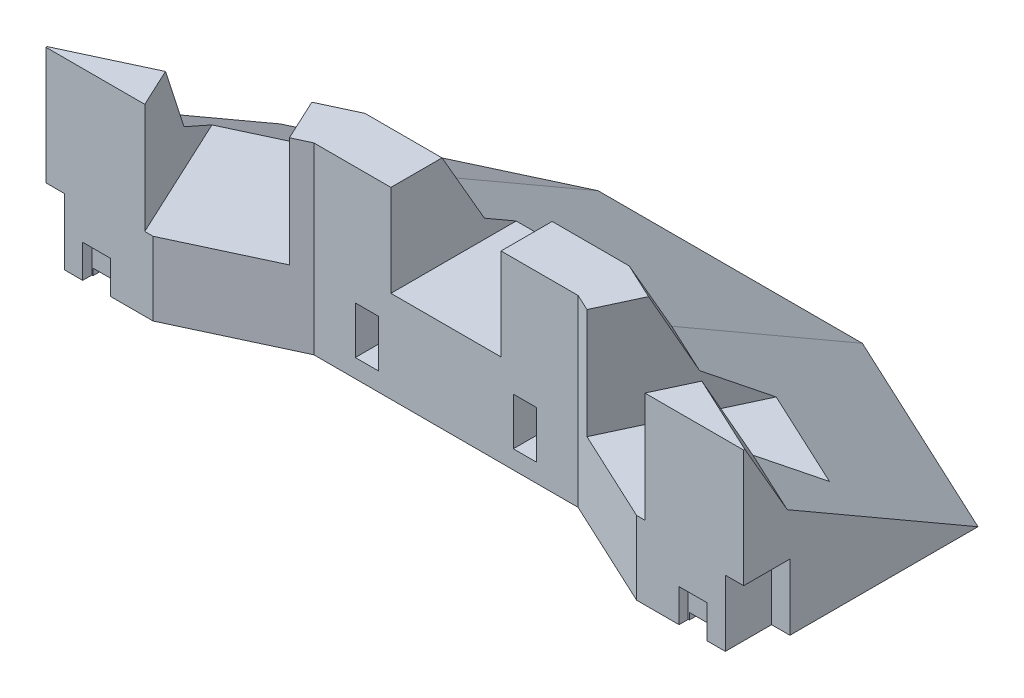
from build123d import *

# Parameters (mm, degrees)
SALIENTE_EXTRUIR1_DEPTH            = 50
CORTAR_EXTRUIR1_DEPTH              = 72
CORTAR_EXTRUIR4_REACH              = 144.211
CROQUIS6_W                         = 30
CROQUIS6_H                         = 25
CORTAR_EXTRUIR5_REACH              = 144.211
CROQUIS8_W                         = 30
CROQUIS8_H                         = 30
CORTAR_EXTRUIR6_DEPTH              = 40
CROQUIS9_W                         = 30
CROQUIS9_H                         = 30
CORTAR_EXTRUIR7_DEPTH              = 40
CROQUIS10_W                        = 6.35
CROQUIS10_H                        = 12.9
CORTAR_EXTRUIR8_DEPTH              = 33
CORTAR_EXTRUIR9_REACH              = 144.211
CORTAR_EXTRUIR10_REACH             = 144.211
CORTAR_EXTRUIR10_DIRECTION_2_DEPTH = 143.210791725
CROQUIS14_W                        = 12.6
CROQUIS14_H                        = 18
CORTAR_EXTRUIR11_DEPTH             = 5
CROQUIS15_W                        = 12.517773713
CROQUIS15_H                        = 18.001366708
CORTAR_EXTRUIR12_DEPTH             = 5
CROQUIS16_W                        = 7.6
CROQUIS16_H                        = 2.5
CORTAR_EXTRUIR13_DEPTH             = 9
CORTAR_EXTRUIR14_DEPTH             = 1.8


with BuildPart() as part:
    # Croquis1 → Saliente-Extruir1 (new body)
    with BuildSketch(Plane(origin=(0, 0, 0), x_dir=(1, 0, 0), z_dir=(0, 1, 0))):
        Polygon((-96.830741331, 0), (96.830741331, 0), (96.830741331, 63), (36, 91.365840534), (-36, 91.365840534), (-96.830741331, 63), align=None)
    extrude(amount=SALIENTE_EXTRUIR1_DEPTH)

    # Croquis3D2 → Cortar-Extruir1 (cut)
    with BuildSketch(Plane(origin=(-36, 0, -91.365840534), x_dir=(0, 0.6600783810393928, 0.751196732477195), z_dir=(-1, 0, 0))):
        Polygon((0, 0), (58.835678645, -11.762776814), (93.598994681, 0), (40.781406688, 46.410941988), align=None)
    extrude(amount=-CORTAR_EXTRUIR1_DEPTH, mode=Mode.SUBTRACT)

    # Cortar-Barrer1: sweep along a curve in space
    with BuildLine() as cortar_barrer1_path:
        Line((96.830741331, 50, -63), (36, 50, -91.365840534))
    # Croquis2 → Cortar-Barrer1 (sweep, cut)
    with BuildSketch(Plane.ZY.offset(-36)):
        Polygon((-91.365840534, 50), (-27.857310923, 50), (-39.404316307, 30), (-91.365840534, 0), align=None)
    sweep(path=cortar_barrer1_path.line, mode=Mode.SUBTRACT)

    # Cortar-Barrer2: sweep along a curve in space
    with BuildLine() as cortar_barrer2_path:
        Line((-36, 50, -91.365840534), (-96.830741331, 50, -63))
    # Croquis3 → Cortar-Barrer2 (sweep, cut)
    with BuildSketch(Plane(origin=(-36, 0, 0), x_dir=(0, 0, -1), z_dir=(1, 0, 0))):
        Polygon((27.857310923, 50), (91.365840534, 50), (91.365840534, 0), (39.404316307, 30), align=None)
    sweep(path=cortar_barrer2_path.line, mode=Mode.SUBTRACT)

    # Croquis6 → Cortar-Extruir4 (cut, up to next)
    with BuildSketch(Plane.XY, mode=Mode.PRIVATE) as cortar_extruir4_sk1:
        with Locations((0, 37.5)):
            Rectangle(CROQUIS6_W, CROQUIS6_H)
    cortar_extruir4_tool1 = extrude(cortar_extruir4_sk1.sketch, amount=-CORTAR_EXTRUIR4_REACH, mode=Mode.PRIVATE) & part.part
    add(cortar_extruir4_tool1.solids().sort_by_distance((0, 37.5, 0))[0], mode=Mode.SUBTRACT)

    # Croquis7 → Cortar-Extruir5 (cut, up to next)
    with BuildSketch(Plane(origin=(0, 50, 0), x_dir=(1, 0, 0), z_dir=(0, 1, 0)), mode=Mode.PRIVATE) as cortar_extruir5_sk1:
        Polygon((-36, 13.928655461), (36, 13.928655461), (65.87009803, 0), (-65.87009803, 0), align=None)
    cortar_extruir5_tool1 = extrude(cortar_extruir5_sk1.sketch, amount=-CORTAR_EXTRUIR5_REACH, mode=Mode.PRIVATE) & part.part
    add(cortar_extruir5_tool1.solids().sort_by_distance((0, 50, -6.28364))[0], mode=Mode.SUBTRACT)

    # Croquis8 → Cortar-Extruir6 (cut)
    with BuildSketch(Plane(origin=(-11.764807584, 0, -25.229711282), x_dir=(0.9063077870366527, 0, -0.4226182617406937), z_dir=(0.4226182617406937, 0, 0.9063077870366527))):
        with Locations((-46.740576174, 35)):
            Rectangle(CROQUIS8_W, CROQUIS8_H)
    extrude(amount=-CORTAR_EXTRUIR6_DEPTH, mode=Mode.SUBTRACT)

    # Croquis9 → Cortar-Extruir7 (cut)
    with BuildSketch(Plane(origin=(11.764807584, 0, -25.229711282), x_dir=(0.9063077870366495, 0, 0.42261826174070066), z_dir=(-0.42261826174070066, 0, 0.9063077870366495))):
        with Locations((46.740576174, 35)):
            Rectangle(CROQUIS9_W, CROQUIS9_H)
    extrude(amount=-CORTAR_EXTRUIR7_DEPTH, mode=Mode.SUBTRACT)

    # Croquis10 → Cortar-Extruir8 (cut)
    with BuildSketch(Plane.XY.offset(-13.928655461)):
        with Locations((-21.525, 11.451366708)):
            Rectangle(CROQUIS10_W, CROQUIS10_H)
        with Locations((21.525, 11.451366708)):
            Rectangle(CROQUIS10_W, CROQUIS10_H)
    extrude(amount=-CORTAR_EXTRUIR8_DEPTH, mode=Mode.SUBTRACT)

    # Croquis12 → Cortar-Extruir9 (cut, up to next)
    with BuildSketch(Plane(origin=(0, 50, 0), x_dir=(1, 0, 0), z_dir=(0, 1, 0)), mode=Mode.PRIVATE) as cortar_extruir9_sk1:
        Polygon((-96.830741331, 0), (-95.030741331, 0), (-95.030741331, 63.839353785), (-96.830741331, 63), align=None)
    cortar_extruir9_tool1 = extrude(cortar_extruir9_sk1.sketch, amount=-CORTAR_EXTRUIR9_REACH, mode=Mode.PRIVATE) & part.part
    add(cortar_extruir9_tool1.solids().sort_by_distance((-95.928756, 50, -31.710301))[0], mode=Mode.SUBTRACT)

    # Croquis13 → Cortar-Extruir10 (cut, up to next)
    with BuildSketch(Plane(origin=(0, 50, 0), x_dir=(1, 0, 0), z_dir=(0, 1, 0)), mode=Mode.PRIVATE) as cortar_extruir10_sk1:
        Polygon((96.830741331, 0), (95.032124755, 0), (95.032124755, 63.838708683), (96.830741331, 63), align=None)
    cortar_extruir10_tool1 = extrude(cortar_extruir10_sk1.sketch, amount=-CORTAR_EXTRUIR10_REACH, mode=Mode.PRIVATE) & part.part
    add(cortar_extruir10_tool1.solids().sort_by_distance((95.929451, 50, -31.710139))[0], mode=Mode.SUBTRACT)

    # Croquis13 → Cortar-Extruir10 direction 2 (cut)
    with BuildSketch(Plane(origin=(0, 50, 0), x_dir=(1, 0, 0), z_dir=(0, 1, 0))):
        Polygon((96.830741331, 0), (95.032124755, 0), (95.032124755, 63.838708683), (96.830741331, 63), align=None)
    extrude(amount=CORTAR_EXTRUIR10_DIRECTION_2_DEPTH, mode=Mode.SUBTRACT)

    # Croquis14 → Cortar-Extruir11 (cut)
    with BuildSketch(Plane(origin=(95.032124755, 0, 0), x_dir=(0, 0, -1), z_dir=(1, 0, 0))):
        with Locations((6.3, 9)):
            Rectangle(CROQUIS14_W, CROQUIS14_H)
    extrude(amount=-CORTAR_EXTRUIR11_DEPTH, mode=Mode.SUBTRACT)

    # Croquis15 → Cortar-Extruir12 (cut)
    with BuildSketch(Plane.ZY.offset(95.030741331)):
        with Locations((-6.258886857, 9.000683354)):
            Rectangle(CROQUIS15_W, CROQUIS15_H)
    extrude(amount=-CORTAR_EXTRUIR12_DEPTH, mode=Mode.SUBTRACT)

    # Croquis16 → Cortar-Extruir13 (cut)
    with BuildSketch(Plane.XZ):
        with Locations((-81.230741331, -1.25)):
            Rectangle(CROQUIS16_W, CROQUIS16_H)
        with Locations((81.232124755, -1.25)):
            Rectangle(CROQUIS16_W, CROQUIS16_H)
    extrude(amount=-CORTAR_EXTRUIR13_DEPTH, mode=Mode.SUBTRACT)

    # Croquis17 → Cortar-Extruir14 (cut)
    with BuildSketch(Plane.XZ):
        Polygon((-81.230741331, -2.5), (-84.730741331, -2.5), (-84.730741331, -13.5), (-77.730741331, -13.5), (-77.730741331, -2.5), align=None)
        Polygon((77.730741331, -13.5), (77.730741331, -2.5), (81.230741331, -2.5), (84.730741331, -2.5), (84.730741331, -13.5), align=None)
    extrude(amount=-CORTAR_EXTRUIR14_DEPTH, mode=Mode.SUBTRACT)


solid = part.part
